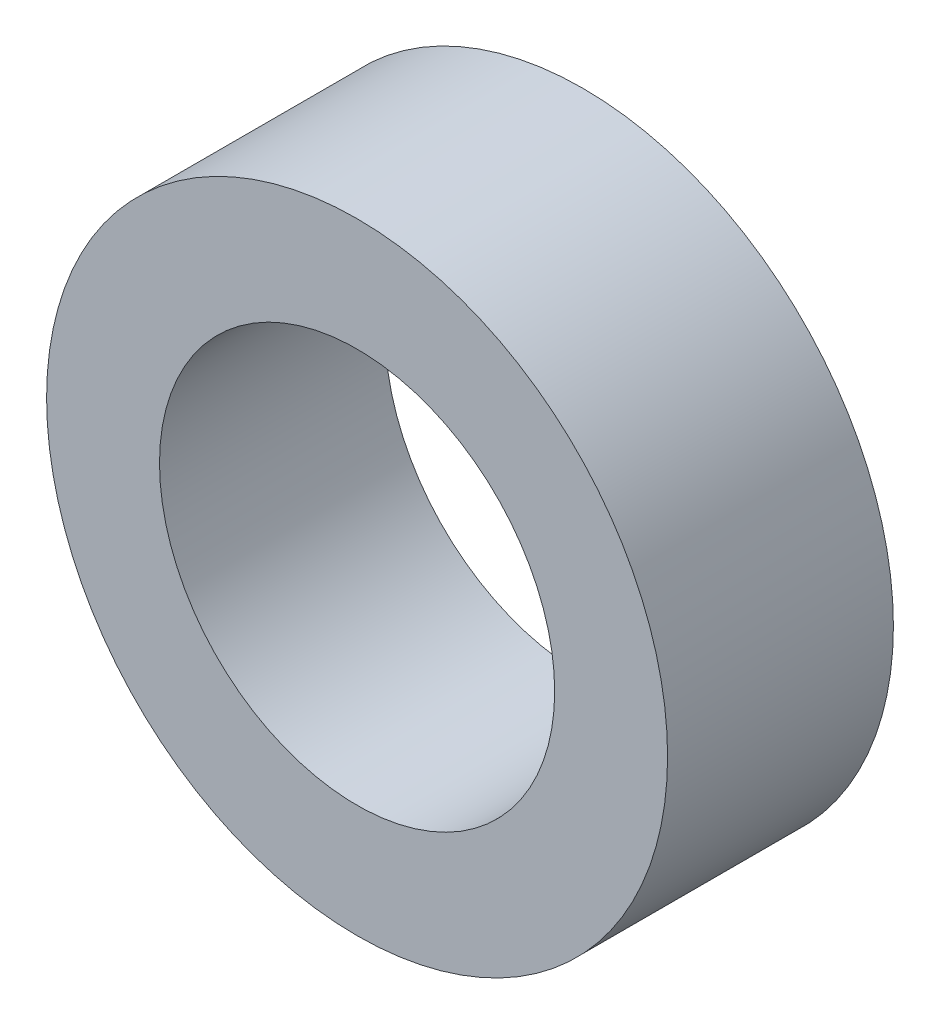
from build123d import *

# Parameters (mm, degrees)
SKETCH1_R           = 44
SKETCH1_R_2         = 28
BOSS_EXTRUDE1_DEPTH = 32


with BuildPart() as part:
    # Sketch1 → Boss-Extrude1 (new body)
    with BuildSketch(Plane.XY):
        Circle(SKETCH1_R)
        Circle(SKETCH1_R_2, mode=Mode.SUBTRACT)
    extrude(amount=BOSS_EXTRUDE1_DEPTH)


solid = part.part
